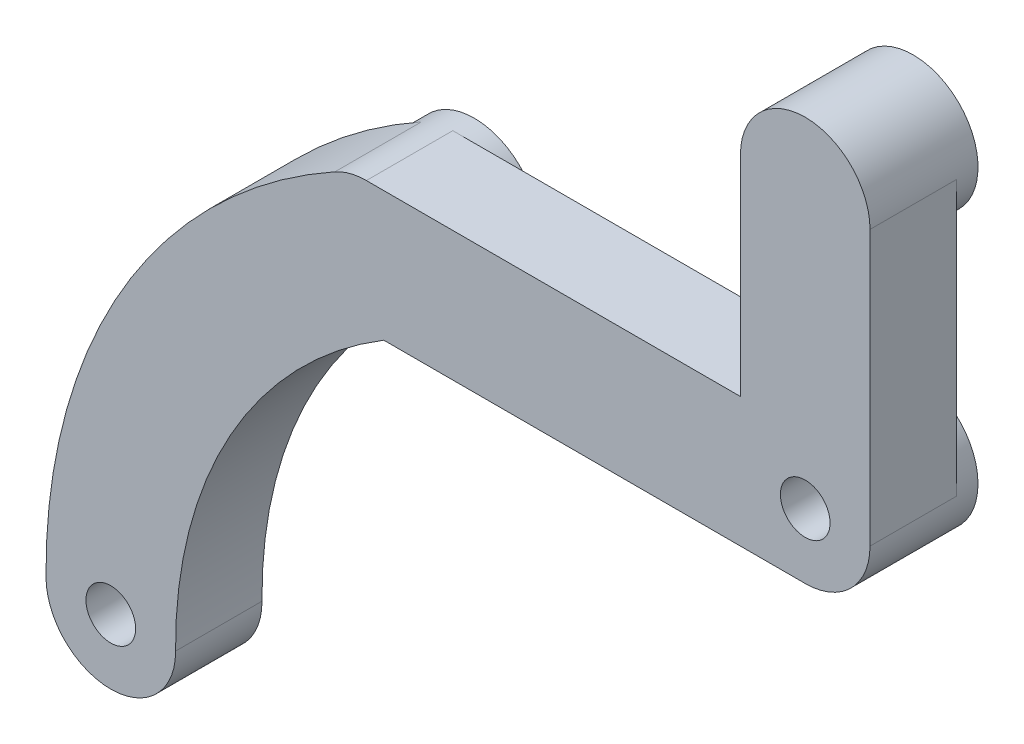
from build123d import *

# Parameters (mm, degrees)
SKIZZE1_R                         = 3
AUFSATZ_LINEAR_AUSTRAGEN1_DEPTH   = 5
AUFSATZ_LINEAR_AUSTRAGEN1_2_DEPTH = 5
AUFSATZ_LINEAR_AUSTRAGEN1_3_DEPTH = 5
SKIZZE2_W                         = 6
SKIZZE2_H                         = 12.7
AUFSATZ_LINEAR_AUSTRAGEN2_DEPTH   = 4
SKIZZE3_W                         = 20.32
SKIZZE3_H                         = 6
AUFSATZ_LINEAR_AUSTRAGEN3_DEPTH   = 4
AUFSATZ_LINEAR_AUSTRAGEN6_DEPTH   = 4
SKIZZE10_R                        = 3
AUFSATZ_LINEAR_AUSTRAGEN7_DEPTH   = 4
SKIZZE11_R                        = 1.7
SCHNITT_LINEAR_AUSTRAGEN5_DEPTH   = 4
SKIZZE12_R                        = 1.15
SCHNITT_LINEAR_AUSTRAGEN6_DEPTH   = 5
SKIZZE14_R                        = 1.15
SCHNITT_LINEAR_AUSTRAGEN8_DEPTH   = 6
SKIZZE15_R                        = 3
SKIZZE15_R_2                      = 1.15
AUFSATZ_LINEAR_AUSTRAGEN9_DEPTH   = 8.13
SKIZZE19_W                        = 52.396987113
SKIZZE19_H                        = 51.888823268
SCHNITT_LINEAR_AUSTRAGEN12_DEPTH  = 4.13


with BuildPart() as part:
    # Skizze1 → Aufsatz-Linear austragen1 (new body)
    with BuildSketch(Plane.XY):
        with Locations((-2.54, 2.54)):
            Circle(SKIZZE1_R)
    extrude(amount=AUFSATZ_LINEAR_AUSTRAGEN1_DEPTH)



with BuildPart() as body_2:
    # Skizze1 → Aufsatz-Linear austragen1 2 (new body)
    with BuildSketch(Plane.XY):
        with Locations((-2.54, 15.24)):
            Circle(SKIZZE1_R)
    extrude(amount=AUFSATZ_LINEAR_AUSTRAGEN1_2_DEPTH)


with BuildPart() as body_3:
    # Skizze1 → Aufsatz-Linear austragen1 3 (new body)
    with BuildSketch(Plane.XY):
        with Locations((-22.86, 2.54)):
            Circle(SKIZZE1_R)
    extrude(amount=AUFSATZ_LINEAR_AUSTRAGEN1_3_DEPTH)


with BuildPart() as part_1:
    add(part.part)

    add(body_2.part)  # Aufsatz-Linear austragen2 merges body 2
    # Skizze2 → Aufsatz-Linear austragen2 (add)
    with BuildSketch(Plane.XY.offset(5)):
        with Locations((-2.54, 8.89)):
            Rectangle(SKIZZE2_W, SKIZZE2_H)
    extrude(amount=-AUFSATZ_LINEAR_AUSTRAGEN2_DEPTH)

    # Skizze3 → Aufsatz-Linear austragen3 (add)
    with BuildSketch(Plane.XY.offset(5)):
        with Locations((-12.7, 2.54)):
            Rectangle(SKIZZE3_W, SKIZZE3_H)
    extrude(amount=-AUFSATZ_LINEAR_AUSTRAGEN3_DEPTH)


    add(body_3.part)  # Aufsatz-Linear austragen6 merges body 3
    # Skizze9 → Aufsatz-Linear austragen6 (add)
    with BuildSketch(Plane(origin=(0, 0, 1), x_dir=(-1, 0, 0), z_dir=(0, 0, -1))):
        with BuildLine():
            Line((21.403833859, -0.082895379), (24.316166141, 5.162895379))
            ThreePointArc((24.316166141, 5.162895379), (34.161496772, -4.480544132), (37.695021225, -17.801229766))
            ThreePointArc((37.695021225, -17.801229766), (34.668329668, -20.774298587), (31.695260847, -17.747607029))
            ThreePointArc((31.695260847, -17.747607029), (28.977165113, -7.500925772), (21.403833859, -0.082895379))
        make_face()
    extrude(amount=-AUFSATZ_LINEAR_AUSTRAGEN6_DEPTH)

    # Skizze10 → Aufsatz-Linear austragen7 (add)
    with BuildSketch(Plane(origin=(0, 0, 1), x_dir=(-1, 0, 0), z_dir=(0, 0, -1))):
        with Locations((34.695141036, -17.774418398)):
            Circle(SKIZZE10_R)
    extrude(amount=-AUFSATZ_LINEAR_AUSTRAGEN7_DEPTH)

    # Skizze11 → Schnitt-Linear austragen5 (cut)
    with BuildSketch(Plane(origin=(0, 0, 0), x_dir=(-1, 0, 0), z_dir=(0, 0, -1))):
        with Locations((2.54, 15.24)):
            Circle(SKIZZE11_R)
        with Locations((22.86, 2.54)):
            Circle(SKIZZE11_R)
    extrude(amount=-SCHNITT_LINEAR_AUSTRAGEN5_DEPTH, mode=Mode.SUBTRACT)

    # Skizze12 → Schnitt-Linear austragen6 (cut, through all)
    with BuildSketch(Plane(origin=(0, 0, 1), x_dir=(-1, 0, 0), z_dir=(0, 0, -1))):
        with Locations((34.695141036, -17.774418398)):
            Circle(SKIZZE12_R)
    extrude(amount=-SCHNITT_LINEAR_AUSTRAGEN6_DEPTH, mode=Mode.SUBTRACT)

    # Skizze14 → Schnitt-Linear austragen8 (cut, through all)
    with BuildSketch(Plane(origin=(0, 0, 0), x_dir=(-1, 0, 0), z_dir=(0, 0, -1))):
        with Locations((2.54, 2.54)):
            Circle(SKIZZE14_R)
    extrude(amount=-SCHNITT_LINEAR_AUSTRAGEN8_DEPTH, mode=Mode.SUBTRACT)

    # Skizze15 → Aufsatz-Linear austragen9 (add)
    with BuildSketch(Plane(origin=(0, 0, 0), x_dir=(-1, 0, 0), z_dir=(0, 0, -1))):
        with Locations((2.54, 2.54)):
            Circle(SKIZZE15_R)
        with Locations((2.54, 2.54)):
            Circle(SKIZZE15_R_2, mode=Mode.SUBTRACT)
    extrude(amount=-AUFSATZ_LINEAR_AUSTRAGEN9_DEPTH)

    # Skizze19 → Schnitt-Linear austragen12 (cut, through all)
    with BuildSketch(Plane.XY.offset(5)):
        with Locations((-20.173492866, -0.896131467)):
            Rectangle(SKIZZE19_W, SKIZZE19_H)
    extrude(amount=SCHNITT_LINEAR_AUSTRAGEN12_DEPTH, mode=Mode.SUBTRACT)


solid = part_1.part
